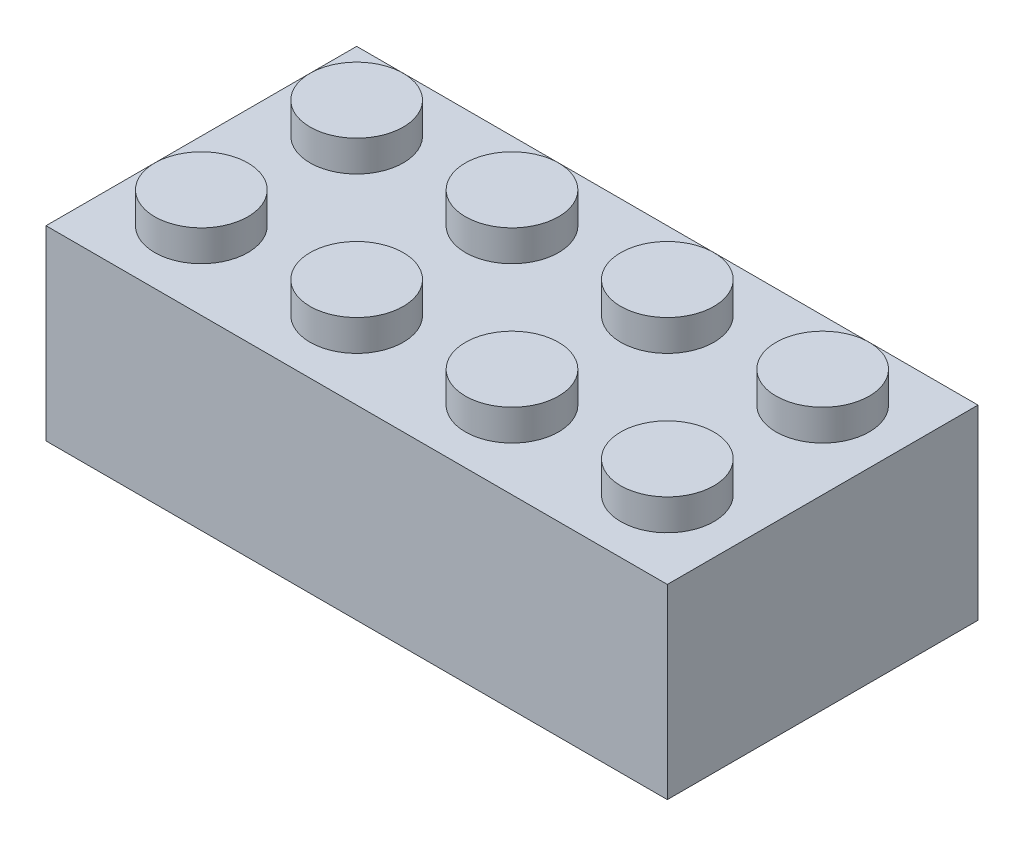
from build123d import *

# Parameters (mm, degrees)
SKETCH1_R             = 1.5
BOSS_EXTRUDE1_DEPTH   = 2
BOSS_EXTRUDE1_2_DEPTH = 2
BOSS_EXTRUDE1_3_DEPTH = 2
BOSS_EXTRUDE1_4_DEPTH = 2
BOSS_EXTRUDE1_5_DEPTH = 2
BOSS_EXTRUDE1_6_DEPTH = 2
BOSS_EXTRUDE1_7_DEPTH = 2
BOSS_EXTRUDE1_8_DEPTH = 2
SKETCH1_3_W           = 20
SKETCH1_3_H           = 10
BOSS_EXTRUDE2_DEPTH   = 1
SKETCH1_4_R           = 0.75
CUT_EXTRUDE1_DEPTH    = 1
SKETCH1_5_W           = 20
SKETCH1_5_H           = 10
SKETCH1_5_W_2         = 18
SKETCH1_5_H_2         = 8
SKETCH1_5_R           = 2.035533906
SKETCH1_5_R_2         = 1.5
BOSS_EXTRUDE3_DEPTH   = 5


with BuildPart() as part:
    # Sketch1 → Boss-Extrude1 (new body)
    with BuildSketch(Plane(origin=(0, 0, 0), x_dir=(1, 0, 0), z_dir=(0, 1, 0))):
        with Locations((-7.5, -2.5)):
            Circle(SKETCH1_R)
    extrude(amount=BOSS_EXTRUDE1_DEPTH)



with BuildPart() as body_2:
    # Sketch1 → Boss-Extrude1 2 (new body)
    with BuildSketch(Plane(origin=(0, 0, 0), x_dir=(1, 0, 0), z_dir=(0, 1, 0))):
        with Locations((-2.5, -2.5)):
            Circle(SKETCH1_R)
    extrude(amount=BOSS_EXTRUDE1_2_DEPTH)


with BuildPart() as body_3:
    # Sketch1 → Boss-Extrude1 3 (new body)
    with BuildSketch(Plane(origin=(0, 0, 0), x_dir=(1, 0, 0), z_dir=(0, 1, 0))):
        with Locations((-7.5, 2.5)):
            Circle(SKETCH1_R)
    extrude(amount=BOSS_EXTRUDE1_3_DEPTH)


with BuildPart() as body_4:
    # Sketch1 → Boss-Extrude1 4 (new body)
    with BuildSketch(Plane(origin=(0, 0, 0), x_dir=(1, 0, 0), z_dir=(0, 1, 0))):
        with Locations((2.5, -2.5)):
            Circle(SKETCH1_R)
    extrude(amount=BOSS_EXTRUDE1_4_DEPTH)


with BuildPart() as body_5:
    # Sketch1 → Boss-Extrude1 5 (new body)
    with BuildSketch(Plane(origin=(0, 0, 0), x_dir=(1, 0, 0), z_dir=(0, 1, 0))):
        with Locations((7.5, -2.5)):
            Circle(SKETCH1_R)
    extrude(amount=BOSS_EXTRUDE1_5_DEPTH)


with BuildPart() as body_6:
    # Sketch1 → Boss-Extrude1 6 (new body)
    with BuildSketch(Plane(origin=(0, 0, 0), x_dir=(1, 0, 0), z_dir=(0, 1, 0))):
        with Locations((-2.5, 2.5)):
            Circle(SKETCH1_R)
    extrude(amount=BOSS_EXTRUDE1_6_DEPTH)


with BuildPart() as body_7:
    # Sketch1 → Boss-Extrude1 7 (new body)
    with BuildSketch(Plane(origin=(0, 0, 0), x_dir=(1, 0, 0), z_dir=(0, 1, 0))):
        with Locations((2.5, 2.5)):
            Circle(SKETCH1_R)
    extrude(amount=BOSS_EXTRUDE1_7_DEPTH)


with BuildPart() as body_8:
    # Sketch1 → Boss-Extrude1 8 (new body)
    with BuildSketch(Plane(origin=(0, 0, 0), x_dir=(1, 0, 0), z_dir=(0, 1, 0))):
        with Locations((7.5, 2.5)):
            Circle(SKETCH1_R)
    extrude(amount=BOSS_EXTRUDE1_8_DEPTH)


with BuildPart() as part_1:
    add(part.part)

    add(body_2.part)  # Boss-Extrude2 merges body 2

    add(body_3.part)  # Boss-Extrude2 merges body 3

    add(body_4.part)  # Boss-Extrude2 merges body 4

    add(body_5.part)  # Boss-Extrude2 merges body 5

    add(body_6.part)  # Boss-Extrude2 merges body 6

    add(body_7.part)  # Boss-Extrude2 merges body 7

    add(body_8.part)  # Boss-Extrude2 merges body 8
    # Sketch1_3 → Boss-Extrude2 (add)
    with BuildSketch(Plane(origin=(0, 0, 0), x_dir=(1, 0, 0), z_dir=(0, 1, 0))):
        Rectangle(SKETCH1_3_W, SKETCH1_3_H)
    extrude(amount=BOSS_EXTRUDE2_DEPTH)

    # Sketch1_4 → Cut-Extrude1 (cut)
    with BuildSketch(Plane(origin=(0, 0, 0), x_dir=(1, 0, 0), z_dir=(0, 1, 0))):
        with Locations((-7.5, 2.5)):
            Circle(SKETCH1_4_R)
        with Locations((-2.5, 2.5)):
            Circle(SKETCH1_4_R)
        with Locations((2.5, 2.5)):
            Circle(SKETCH1_4_R)
        with Locations((7.5, 2.5)):
            Circle(SKETCH1_4_R)
        with Locations((-2.5, -2.5)):
            Circle(SKETCH1_4_R)
        with Locations((2.5, -2.5)):
            Circle(SKETCH1_4_R)
        with Locations((7.5, -2.5)):
            Circle(SKETCH1_4_R)
        with Locations((-7.5, -2.5)):
            Circle(SKETCH1_4_R)
    extrude(amount=CUT_EXTRUDE1_DEPTH, mode=Mode.SUBTRACT)

    # Sketch1_5 → Boss-Extrude3 (add)
    # profile 1 of 4: a face of its own
    with BuildSketch(Plane(origin=(0, 0, 0), x_dir=(1, 0, 0), z_dir=(0, 1, 0))):
        Rectangle(SKETCH1_5_W, SKETCH1_5_H)
        Rectangle(SKETCH1_5_W_2, SKETCH1_5_H_2, mode=Mode.SUBTRACT)
    # profile 2 of 4: a face of its own
    with BuildSketch(Plane(origin=(0, 0, 0), x_dir=(1, 0, 0), z_dir=(0, 1, 0))):
        with Locations((-5, 0)):
            Circle(SKETCH1_5_R)
        with Locations((-5, 0)):
            Circle(SKETCH1_5_R_2, mode=Mode.SUBTRACT)
    # profile 3 of 4: a face of its own
    with BuildSketch(Plane(origin=(0, 0, 0), x_dir=(1, 0, 0), z_dir=(0, 1, 0))):
        Circle(SKETCH1_5_R)
        Circle(SKETCH1_5_R_2, mode=Mode.SUBTRACT)
    # profile 4 of 4: a face of its own
    with BuildSketch(Plane(origin=(0, 0, 0), x_dir=(1, 0, 0), z_dir=(0, 1, 0))):
        with Locations((5, 0)):
            Circle(SKETCH1_5_R)
        with Locations((5, 0)):
            Circle(SKETCH1_5_R_2, mode=Mode.SUBTRACT)
    extrude(amount=-BOSS_EXTRUDE3_DEPTH)


solid = part_1.part
